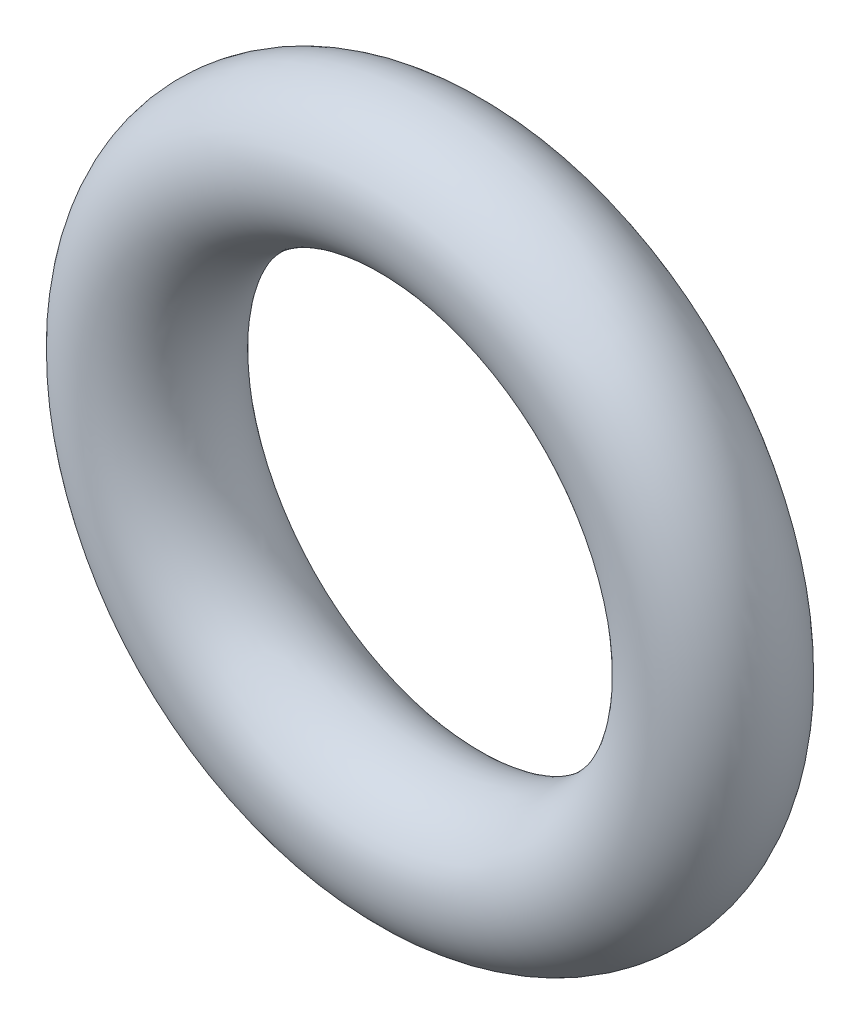
from build123d import *

# Parameters (mm, degrees)
SKETCH2_R = 0.889


with BuildPart() as part:
    # Sketch2 → Revolve1 (revolve)
    with BuildSketch(Plane(origin=(0, 0, 0), x_dir=(0, 0, -1), z_dir=(1, 0, 0))):
        with Locations((0, -3.5306)):
            Circle(SKETCH2_R)
    revolve(axis=Axis((0, 0, 0.889), (0, 0, -1)))


solid = part.part
